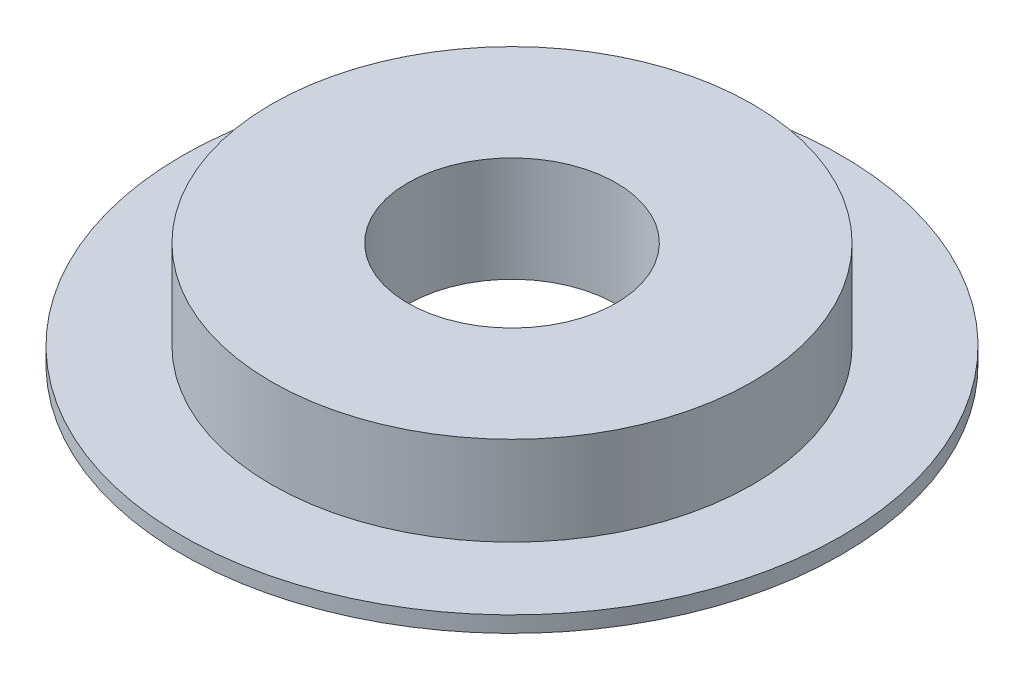
from build123d import *


with BuildPart() as part:
    # Croquis1 → Revolución1 (revolve)
    with BuildSketch(Plane.XY):
        Polygon((-40.72158728, 8.972889318), (-40.72158728, -2.827110682), (-66.02158728, -2.827110682), (-66.02158728, -1.027110682), (-56.02158728, -1.027110682), (-56.02158728, 8.972889318), align=None)
    revolve(axis=Axis((-29.02158728, 13.972889318, 0), (0, -1, 0)))


solid = part.part
